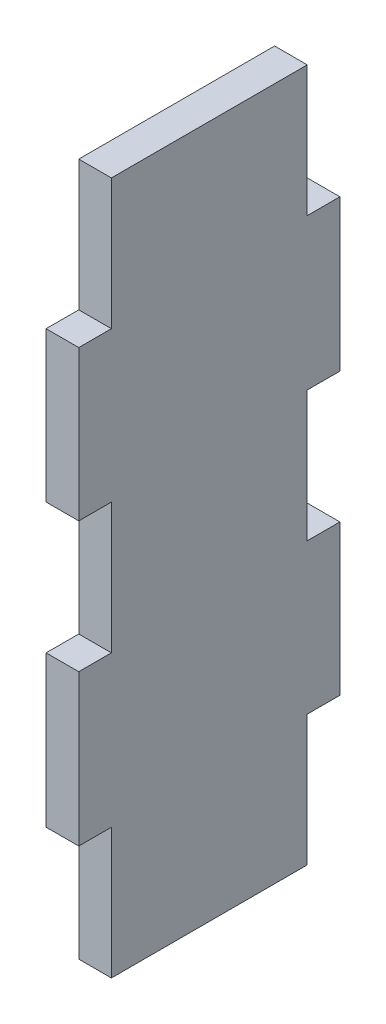
from build123d import *

# Parameters (mm, degrees)
SKETCH1_W           = 3.175
SKETCH1_H           = 67.394244588
BOSS_EXTRUDE1_DEPTH = 25.4
SKETCH2_W           = 3.175
SKETCH2_H           = 12.7
CUT_EXTRUDE1_DEPTH  = 3.175


with BuildPart() as part:
    # Sketch1 → Boss-Extrude1 (new body)
    with BuildSketch(Plane.XY):
        with Locations((452.694995352, 153.478391554)):
            Rectangle(SKETCH1_W, SKETCH1_H)
    extrude(amount=-BOSS_EXTRUDE1_DEPTH)

    # Sketch2 → Cut-Extrude1 (cut)
    with BuildSketch(Plane(origin=(454.282495352, 0, 0), x_dir=(0, 0, -1), z_dir=(1, 0, 0))):
        with Locations((1.5875, 180.825513848)):
            Rectangle(SKETCH2_W, SKETCH2_H)
        with Locations((23.8125, 180.825513848)):
            Rectangle(SKETCH2_W, SKETCH2_H)
        with Locations((23.8125, 126.13126926)):
            Rectangle(SKETCH2_W, SKETCH2_H)
        with Locations((1.5875, 126.13126926)):
            Rectangle(SKETCH2_W, SKETCH2_H)
        with Locations((1.5875, 153.520513848)):
            Rectangle(SKETCH2_W, SKETCH2_H)
        with Locations((23.8125, 153.43626926)):
            Rectangle(SKETCH2_W, SKETCH2_H)
    extrude(amount=-CUT_EXTRUDE1_DEPTH, mode=Mode.SUBTRACT)


solid = part.part
